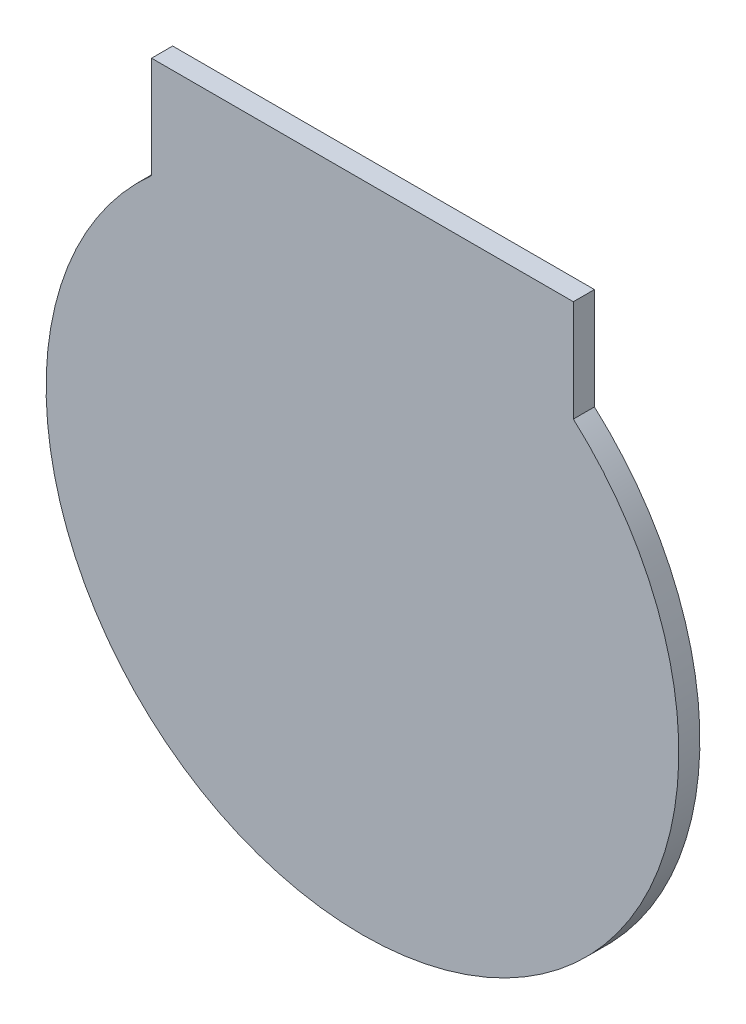
from build123d import *

# Parameters (mm, degrees)
RESSALTO_EXTRUS_O1_DEPTH = 5


with BuildPart() as part:
    # Esboço1 → Ressalto-extrusão1 (new body)
    with BuildSketch(Plane.XY):
        with BuildLine():
            Line((-55.504594539, -168.430491325), (-55.504594539, -144.332190763))
            Line((-55.504594539, -144.332190763), (44.495405461, -144.332190763))
            Line((44.495405461, -144.332190763), (44.495405461, -168.430491325))
            ThreePointArc((44.495405461, -168.430491325), (-5.504594539, -299.332190763), (-55.504594539, -168.430491325))
        make_face()
    extrude(amount=RESSALTO_EXTRUS_O1_DEPTH)


solid = part.part
